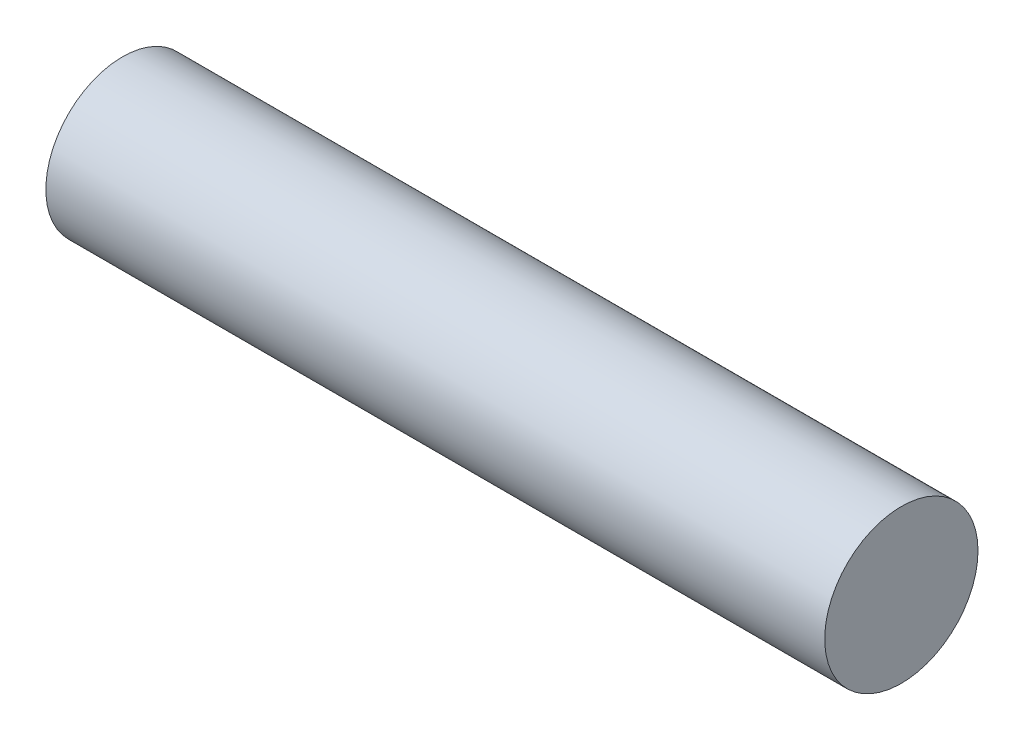
from build123d import *

# Parameters (mm, degrees)
SKETCH1_R           = 5
BOSS_EXTRUDE1_DEPTH = 25.4


with BuildPart() as part:
    # Sketch1 → Boss-Extrude1 (new body, symmetric)
    with BuildSketch(Plane(origin=(0, 0, 0), x_dir=(0, 0, -1), z_dir=(1, 0, 0))):
        Circle(SKETCH1_R)
    extrude(amount=BOSS_EXTRUDE1_DEPTH, both=True)


solid = part.part
